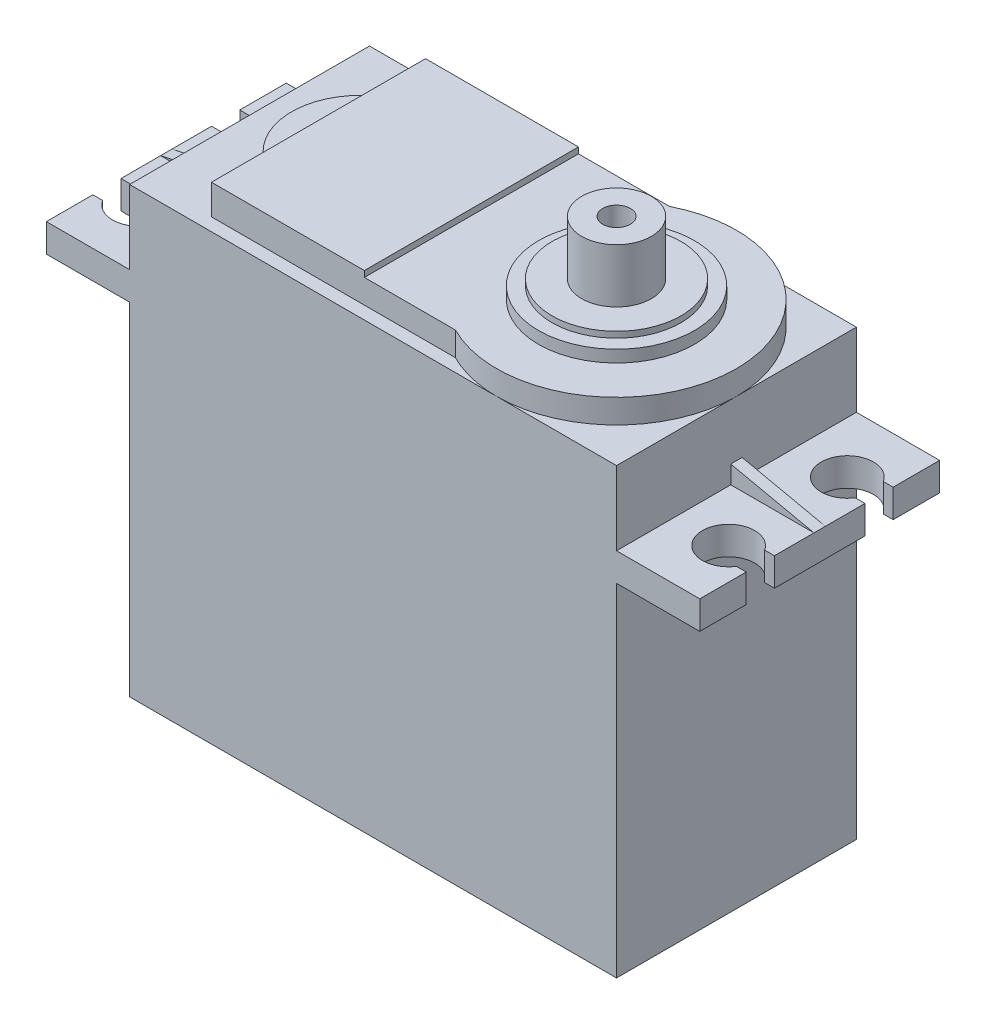
from build123d import *

# Parameters (mm, degrees)
SKETCH1_W           = 40.6
SKETCH1_H           = 20
BOSS_EXTRUDE1_DEPTH = 37
BOSS_EXTRUDE2_START = 28.5
SKETCH2_W           = 6.94
SKETCH2_H           = 20
BOSS_EXTRUDE2_DEPTH = 2.35
BOSS_EXTRUDE8_DEPTH = 0.475
SKETCH3_W           = 2.645
SKETCH3_H           = 2.35
CUT_EXTRUDE2_DEPTH  = 31.85
BOSS_EXTRUDE4_DEPTH = 2
SKETCH6_W           = 12.75
SKETCH6_H           = 17.85
BOSS_EXTRUDE5_DEPTH = 0.5
SKETCH7_R           = 6.5
BOSS_EXTRUDE6_DEPTH = 1
SKETCH8_R           = 5.375
BOSS_EXTRUDE7_DEPTH = 0.5
BOSS_EXTRUDE3_START = 2
SKETCH4_R           = 2.9
SKETCH4_R_2         = 1.15
BOSS_EXTRUDE3_DEPTH = 6


with BuildPart() as part:
    # Sketch1 → Boss-Extrude1 (new body)
    with BuildSketch(Plane(origin=(0, 0, 0), x_dir=(1, 0, 0), z_dir=(0, 1, 0))):
        Rectangle(SKETCH1_W, SKETCH1_H)
    extrude(amount=BOSS_EXTRUDE1_DEPTH)

    # Sketch2 → Boss-Extrude2 (add)
    with BuildSketch(Plane(origin=(0, 0, 0), x_dir=(1, 0, 0), z_dir=(0, 1, 0)).offset(BOSS_EXTRUDE2_START)):
        with Locations((23.77, 0)):
            Rectangle(SKETCH2_W, SKETCH2_H)
    boss_extrude2 = extrude(amount=BOSS_EXTRUDE2_DEPTH)

    # Sketch3 → Cut-Extrude2 (cut, through all)
    with BuildSketch(Plane(origin=(0, 30.85, 0), x_dir=(1, 0, 0), z_dir=(0, 1, 0))):
        with BuildLine():
            ThreePointArc((26.425300522, 6.125), (22.42, 4.95), (26.425300522, 3.775))
            Line((26.425300522, 3.775), (24.595, 3.775))
            Line((24.595, 3.775), (24.595, 6.125))
            Line((24.595, 6.125), (26.425300522, 6.125))
        make_face()
        with BuildLine():
            Line((24.595, 3.775), (26.425300522, 3.775))
            ThreePointArc((26.425300522, 3.775), (26.682046793, 4.337741327), (26.77, 4.95))
            ThreePointArc((26.77, 4.95), (26.682046793, 5.562258673), (26.425300522, 6.125))
            Line((26.425300522, 6.125), (24.595, 6.125))
            Line((24.595, 6.125), (24.595, 3.775))
        make_face()
        with Locations((28.5625, 4.95)):
            Rectangle(SKETCH3_W, SKETCH3_H)
        with BuildLine():
            Line((26.425300522, 3.775), (27.24, 3.775))
            Line((27.24, 3.775), (27.24, 6.125))
            Line((27.24, 6.125), (26.425300522, 6.125))
            ThreePointArc((26.425300522, 6.125), (26.682046793, 5.562258673), (26.77, 4.95))
            ThreePointArc((26.77, 4.95), (26.682046793, 4.337741327), (26.425300522, 3.775))
        make_face()
        with BuildLine():
            ThreePointArc((26.425300522, -3.775), (22.42, -4.95), (26.425300522, -6.125))
            Line((26.425300522, -6.125), (24.595, -6.125))
            Line((24.595, -6.125), (24.595, -3.775))
            Line((24.595, -3.775), (26.425300522, -3.775))
        make_face()
        with BuildLine():
            Line((24.595, -6.125), (26.425300522, -6.125))
            ThreePointArc((26.425300522, -6.125), (26.682046793, -5.562258673), (26.77, -4.95))
            ThreePointArc((26.77, -4.95), (26.682046793, -4.337741327), (26.425300522, -3.775))
            Line((26.425300522, -3.775), (24.595, -3.775))
            Line((24.595, -3.775), (24.595, -6.125))
        make_face()
        with Locations((28.5625, -4.95)):
            Rectangle(SKETCH3_W, SKETCH3_H)
        with BuildLine():
            Line((26.425300522, -6.125), (27.24, -6.125))
            Line((27.24, -6.125), (27.24, -3.775))
            Line((27.24, -3.775), (26.425300522, -3.775))
            ThreePointArc((26.425300522, -3.775), (26.682046793, -4.337741327), (26.77, -4.95))
            ThreePointArc((26.77, -4.95), (26.682046793, -5.562258673), (26.425300522, -6.125))
        make_face()
    cut_extrude2 = extrude(amount=-CUT_EXTRUDE2_DEPTH, mode=Mode.SUBTRACT)

    # Mirror2: Boss-Extrude2, Cut-Extrude2 across plane
    add(boss_extrude2.mirror(Plane(origin=(0, 0, 0), x_dir=(0, 0, 1), z_dir=(1, 0, 0))))
    add(cut_extrude2.mirror(Plane(origin=(0, 0, 0), x_dir=(0, 0, 1), z_dir=(1, 0, 0))), mode=Mode.SUBTRACT)


with BuildPart() as body_2:
    # Sketch10 → Boss-Extrude8 (new body, symmetric)
    with BuildSketch(Plane.XY):
        Polygon((20.3, 32.35), (27.24, 30.85), (27.24, 30.331456629), (19.880126177, 30.331456629), (19.880126177, 32.35), align=None)
    boss_extrude8 = extrude(amount=BOSS_EXTRUDE8_DEPTH, both=True)


with BuildPart() as part_1:
    add(part.part)

    # Mirror6: Boss-Extrude8 across plane
    add(boss_extrude8.mirror(Plane(origin=(0, 0, 0), x_dir=(0, 0, 1), z_dir=(1, 0, 0))))

    # Sketch5 → Boss-Extrude4 (add)
    with BuildSketch(Plane(origin=(0, 37, 0), x_dir=(1, 0, 0), z_dir=(0, 1, 0))):
        with BuildLine():
            Line((-14.55, -4.55), (-14.55, -8.925))
            Line((-14.55, -8.925), (5.789526078, -8.925))
            ThreePointArc((5.789526078, -8.925), (20.3, 0), (5.789526078, 8.925))
            Line((5.789526078, 8.925), (-14.55, 8.925))
            Line((-14.55, 8.925), (-14.55, 4.55))
            ThreePointArc((-14.55, 4.55), (-16.8, 0), (-14.55, -4.55))
        make_face()
    extrude(amount=BOSS_EXTRUDE4_DEPTH)

    # Sketch6 → Boss-Extrude5 (add)
    with BuildSketch(Plane(origin=(0, 39, 0), x_dir=(1, 0, 0), z_dir=(0, 1, 0))):
        with Locations((-8.175, 0)):
            Rectangle(SKETCH6_W, SKETCH6_H)
    extrude(amount=BOSS_EXTRUDE5_DEPTH)

    # Sketch7 → Boss-Extrude6 (add)
    with BuildSketch(Plane(origin=(0, 39, 0), x_dir=(1, 0, 0), z_dir=(0, 1, 0))):
        with Locations((10.3, 0)):
            Circle(SKETCH7_R)
    extrude(amount=BOSS_EXTRUDE6_DEPTH)

    # Sketch8 → Boss-Extrude7 (add)
    with BuildSketch(Plane(origin=(0, 40, 0), x_dir=(1, 0, 0), z_dir=(0, 1, 0))):
        with Locations((10.3, 0)):
            Circle(SKETCH8_R)
    extrude(amount=BOSS_EXTRUDE7_DEPTH)

    # Sketch4 → Boss-Extrude3 (add)
    with BuildSketch(Plane(origin=(0, 37, 0), x_dir=(1, 0, 0), z_dir=(0, 1, 0)).offset(BOSS_EXTRUDE3_START)):
        with Locations((10.3, 0)):
            Circle(SKETCH4_R)
        with Locations((10.3, 0)):
            Circle(SKETCH4_R_2, mode=Mode.SUBTRACT)
    extrude(amount=BOSS_EXTRUDE3_DEPTH)


solid = Compound([body_2.part, part_1.part])
